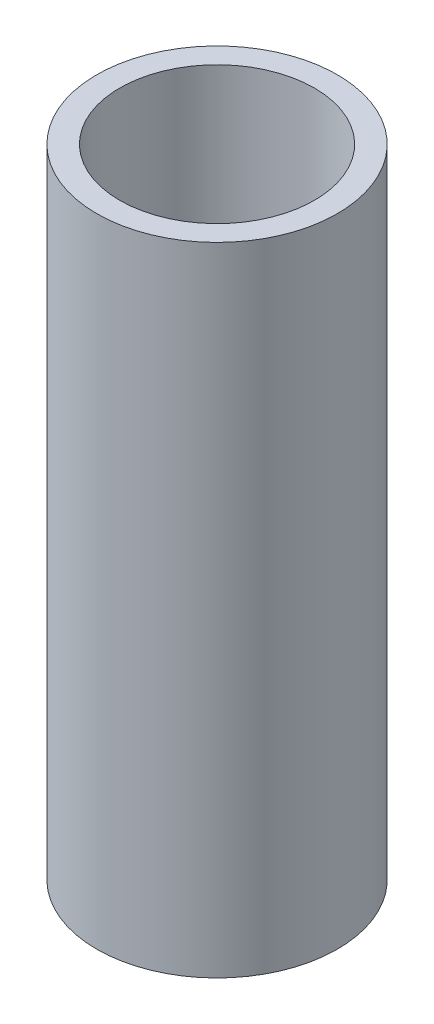
from build123d import *

# Parameters (mm, degrees)
SKETCH1_R           = 34
BOSS_EXTRUDE1_DEPTH = 180
SKETCH2_R           = 27.5
CUT_EXTRUDE1_DEPTH  = 181
SKETCH3_R           = 28.5
SKETCH3_R_2         = 27.5
CUT_EXTRUDE2_DEPTH  = 2


with BuildPart() as part:
    # Sketch1 → Boss-Extrude1 (new body)
    with BuildSketch(Plane(origin=(0, 0, 0), x_dir=(1, 0, 0), z_dir=(0, 1, 0))):
        Circle(SKETCH1_R)
    extrude(amount=BOSS_EXTRUDE1_DEPTH)

    # Sketch2 → Cut-Extrude1 (cut, through all)
    with BuildSketch(Plane.XZ):
        Circle(SKETCH2_R)
    extrude(amount=-CUT_EXTRUDE1_DEPTH, mode=Mode.SUBTRACT)

    # Sketch3 → Cut-Extrude2 (cut)
    with BuildSketch(Plane(origin=(0, 39, 0), x_dir=(-1, 0, 0), z_dir=(0, -1, 0))):
        Circle(SKETCH3_R)
        Circle(SKETCH3_R_2, mode=Mode.SUBTRACT)
    extrude(amount=CUT_EXTRUDE2_DEPTH, mode=Mode.SUBTRACT)


solid = part.part
